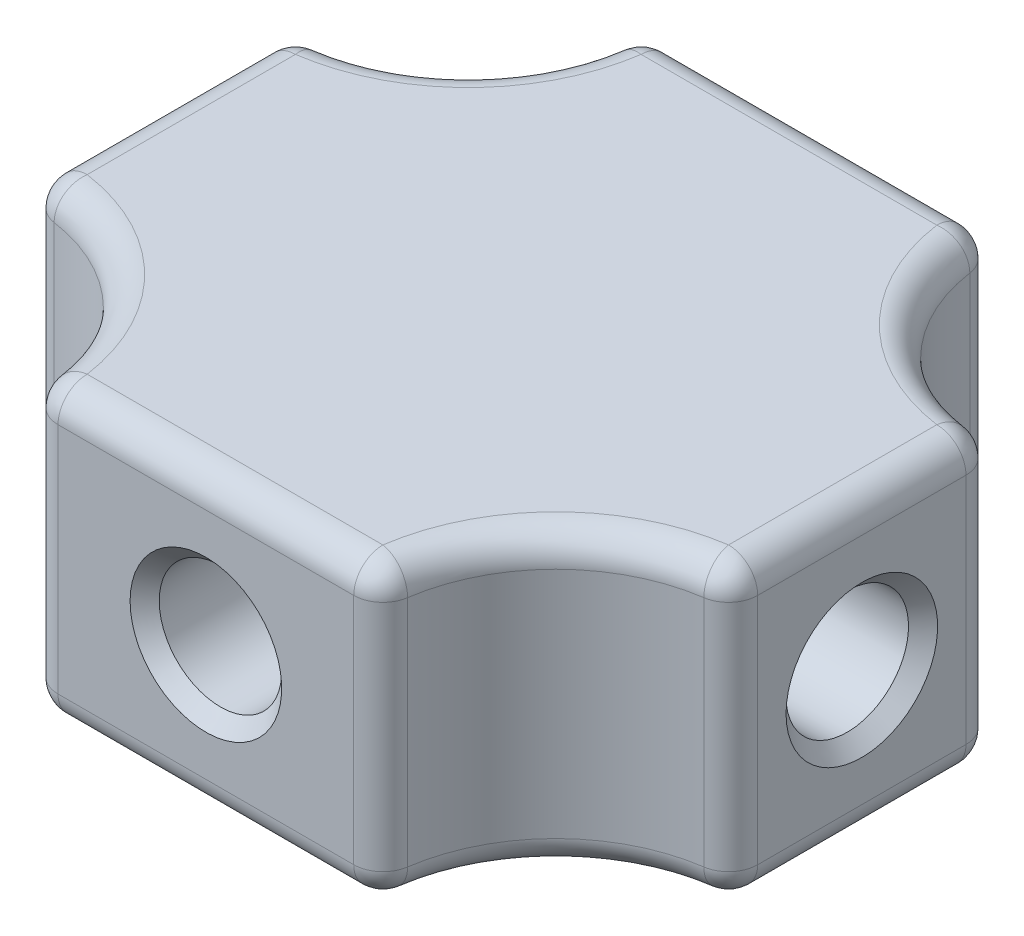
from build123d import *

# Parameters (mm, degrees)
SKIZZE1_W                            = 24
SKIZZE1_H                            = 21
AUFSATZ_LINEAR_AUSTRAGEN1_DEPTH      = 10
SKIZZE2_R                            = 2.1
SCHNITT_LINEAR_AUSTRAGEN1_DEPTH      = 20
SCHNITT_LINEAR_AUSTRAGEN1_DEPTH_BACK = 20
SKIZZE3_R                            = 2.1
SCHNITT_LINEAR_AUSTRAGEN2_DEPTH      = 20
SCHNITT_LINEAR_AUSTRAGEN2_DEPTH_BACK = 20
SKIZZE4_R                            = 6
SCHNITT_LINEAR_AUSTRAGEN3_DEPTH      = 10
VERRUNDUNG1_R                        = 1
VERRUNDUNG2_R                        = 1
FASE1_SIZE                           = 0.5


with BuildPart() as part:
    # Skizze1 → Aufsatz-Linear austragen1 (new body)
    with BuildSketch(Plane(origin=(0, 0, 0), x_dir=(1, 0, 0), z_dir=(0, 1, 0))):
        Rectangle(SKIZZE1_W, SKIZZE1_H)
    extrude(amount=AUFSATZ_LINEAR_AUSTRAGEN1_DEPTH)

    # Skizze2 → Schnitt-Linear austragen1 (cut, two sides)
    with BuildSketch(Plane(origin=(0, 0, 0), x_dir=(0, 0, -1), z_dir=(1, 0, 0))) as schnitt_linear_austragen1_sk:
        with Locations((0, 5)):
            Circle(SKIZZE2_R)
    extrude(amount=SCHNITT_LINEAR_AUSTRAGEN1_DEPTH, mode=Mode.SUBTRACT)
    extrude(schnitt_linear_austragen1_sk.sketch, amount=-SCHNITT_LINEAR_AUSTRAGEN1_DEPTH_BACK, mode=Mode.SUBTRACT)

    # Skizze3 → Schnitt-Linear austragen2 (cut, two sides)
    with BuildSketch(Plane.XY) as schnitt_linear_austragen2_sk:
        with Locations((0, 5)):
            Circle(SKIZZE3_R)
    extrude(amount=SCHNITT_LINEAR_AUSTRAGEN2_DEPTH, mode=Mode.SUBTRACT)
    extrude(schnitt_linear_austragen2_sk.sketch, amount=-SCHNITT_LINEAR_AUSTRAGEN2_DEPTH_BACK, mode=Mode.SUBTRACT)

    # Skizze4 → Schnitt-Linear austragen3 (cut)
    with BuildSketch(Plane(origin=(0, 10, 0), x_dir=(-1, 0, 0), z_dir=(0, 1, 0))):
        with Locations((12, -10.5)):
            Circle(SKIZZE4_R)
        with Locations((-12, -10.5)):
            Circle(SKIZZE4_R)
        with Locations((-12, 10.5)):
            Circle(SKIZZE4_R)
        with Locations((12, 10.5)):
            Circle(SKIZZE4_R)
    extrude(amount=-SCHNITT_LINEAR_AUSTRAGEN3_DEPTH, mode=Mode.SUBTRACT)

    # Verrundung1
    verrundung1_edges = [part.edges().sort_by_distance(p)[0] for p in [
        (-6, 5, -10.5),
        (-12, 5, -4.5),
        (6, 5, -10.5),
        (12, 5, -4.5),
        (6, 5, 10.5),
        (12, 5, 4.5),
        (-6, 5, 10.5),
        (-12, 5, 4.5),
    ]]
    fillet(verrundung1_edges, radius=VERRUNDUNG1_R)

    # Verrundung2
    verrundung2_edges = [part.edges().sort_by_distance(p)[0] for p in [
        (12, 10, 0),
        (12, 0, 0),
        (0, 0, 10.5),
        (-7.757359313, 0, 6.257359313),
        (-12, 0, 0),
        (-7.757359313, 0, -6.257359313),
        (0, 0, -10.5),
        (7.757359313, 0, -6.257359313),
        (7.757359313, 0, 6.257359313),
        (11.755928946, 0, -4.22645044),
        (5.72645044, 0, -10.255928946),
        (-5.72645044, 0, -10.255928946),
        (-11.755928946, 0, -4.22645044),
        (-11.755928946, 0, 4.22645044),
        (-5.72645044, 0, 10.255928946),
        (5.72645044, 0, 10.255928946),
        (11.755928946, 0, 4.22645044),
        (7.757359313, 10, 6.257359313),
        (-7.757359313, 10, 6.257359313),
        (0, 10, 10.5),
        (7.757359313, 10, -6.257359313),
        (0, 10, -10.5),
        (-7.757359313, 10, -6.257359313),
        (-12, 10, 0),
        (11.755928946, 10, -4.22645044),
        (5.72645044, 10, -10.255928946),
        (-5.72645044, 10, -10.255928946),
        (-11.755928946, 10, -4.22645044),
        (-11.755928946, 10, 4.22645044),
        (-5.72645044, 10, 10.255928946),
        (5.72645044, 10, 10.255928946),
        (11.755928946, 10, 4.22645044),
    ]]
    fillet(verrundung2_edges, radius=VERRUNDUNG2_R)

    # Fase1
    fase1_edges = [part.edges().sort_by_distance(p)[0] for p in [
        (-12, 5, 2.1),
        (12, 5, 2.1),
        (-2.1, 5, -10.5),
        (-2.1, 5, 10.5),
    ]]
    chamfer(fase1_edges, length=FASE1_SIZE)


solid = part.part
